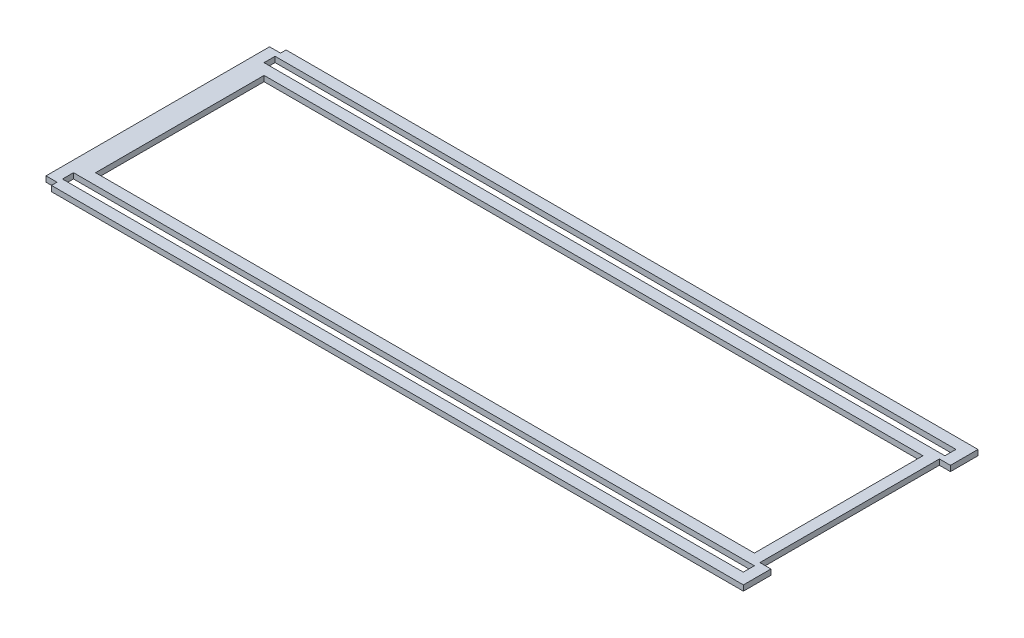
from build123d import *

# Parameters (mm, degrees)
SKETCH1_W           = 393.6492
SKETCH1_H           = 6.4008
SKETCH1_W_2         = 380.8984
SKETCH1_H_2         = 97.44075
BOSS_EXTRUDE1_DEPTH = 3.175


with BuildPart() as part:
    # Sketch1 → Boss-Extrude1 (new body)
    with BuildSketch(Plane(origin=(0, 0, 0), x_dir=(1, 0, 0), z_dir=(0, 1, 0))):
        Polygon((-203.2, 64.620775), (-203.2, -64.620775), (-196.85, -64.620775), (-196.85, -67.821175), (203.2, -67.821175), (203.2, -51.895375), (196.7992, -51.895375), (196.7992, 51.895375), (203.2, 51.895375), (203.2, 67.821175), (-196.85, 67.821175), (-196.85, 64.620775), align=None)
        with Locations((-0.0254, 58.270775)):
            Rectangle(SKETCH1_W, SKETCH1_H, mode=Mode.SUBTRACT)
        with Locations((-0.0254, -58.270775)):
            Rectangle(SKETCH1_W, SKETCH1_H, mode=Mode.SUBTRACT)
        Rectangle(SKETCH1_W_2, SKETCH1_H_2, mode=Mode.SUBTRACT)
    extrude(amount=BOSS_EXTRUDE1_DEPTH)


solid = part.part
